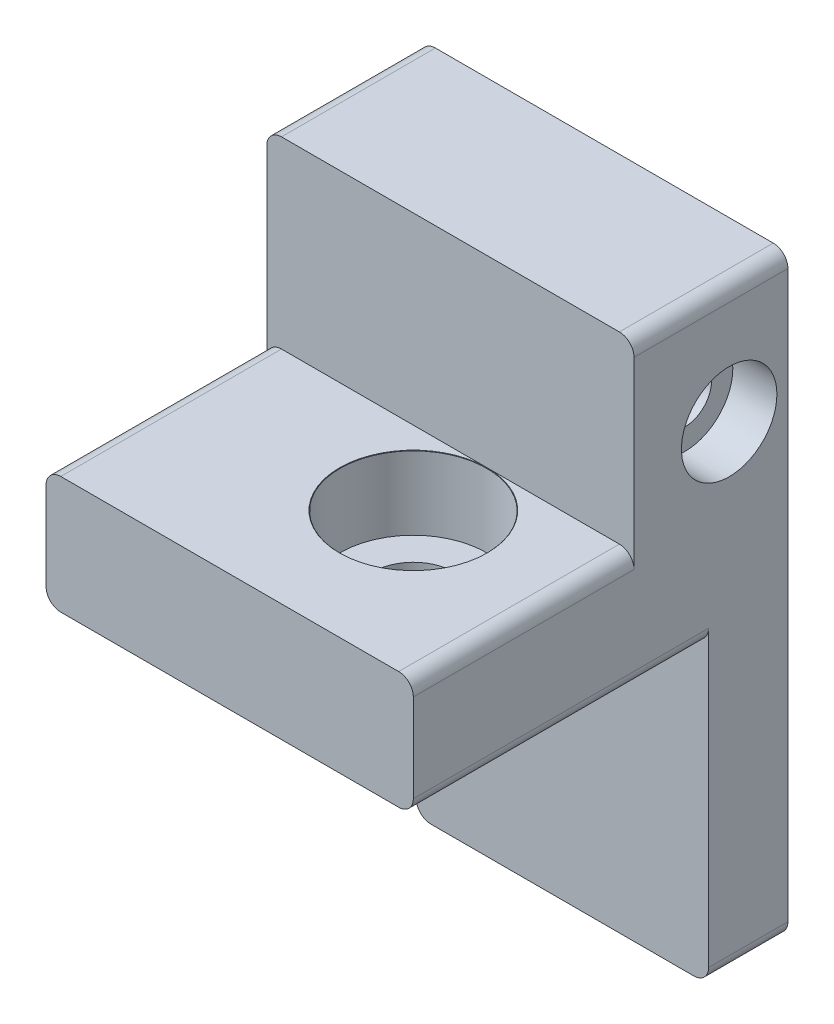
from build123d import *

# Parameters (mm, degrees)
BOSS_EXTRUDE1_DEPTH            = 8
CBORE_FOR_M5_SHCS1_AT_2_COUNT  = 2
CBORE_FOR_M5_SHCS1_AT_2_PITCH  = 20
SKETCH5_W                      = 25
SKETCH5_H                      = 2.975
BOSS_EXTRUDE2_DEPTH            = 12.51
SKETCH6_W                      = 3
SKETCH6_H                      = 8.01
BOSS_EXTRUDE3_DEPTH            = 7.5
BOSS_EXTRUDE4_DEPTH            = 5.5
SKETCH8_W                      = 17
SKETCH8_H                      = 1.25
BOSS_EXTRUDE5_DEPTH            = 7.5
BOSS_EXTRUDE6_DEPTH            = 5.4
FILLET2_R                      = 1
CBORE_FOR_M3_SHCS1_D           = 3.6
CBORE_FOR_M3_SHCS1_DEPTH       = 5
CBORE_FOR_M3_SHCS1_CBORE_D     = 6.5
CBORE_FOR_M3_SHCS1_CBORE_DEPTH = 3
SKETCH13_R                     = 2.4
CUT_EXTRUDE1_DEPTH             = 3.8
SKETCH14_R                     = 1.65
CUT_EXTRUDE2_DEPTH             = 3
SKETCH15_W                     = 20
SKETCH15_H                     = 20
CUT_EXTRUDE3_DEPTH             = 29
SKETCH16_W                     = 17
SKETCH16_H                     = 0.2
SKETCH16_W_2                   = 3
SKETCH16_H_2                   = 0.3
CUT_EXTRUDE4_DEPTH             = 7.5


with BuildPart() as part:
    # Sketch1 → Boss-Extrude1 (new body)
    with BuildSketch(Plane(origin=(0, 0, 0), x_dir=(1, 0, 0), z_dir=(0, 1, 0))):
        Polygon((-10, 0), (-15, 0), (-15, 20), (-10, 20), (10, 20), (10, -20), (-10, -20), align=None)
    extrude(amount=BOSS_EXTRUDE1_DEPTH)

    # Sketch4 → CBORE for M5 SHCS1 (revolve, cut)
    with BuildSketch(Plane(origin=(0, 8, -10), x_dir=(0, 0, 1), z_dir=(1, 0, 0))):
        Polygon((0, 0), (0, 8), (2.75, 8), (2.75, 5), (5, 5), (5, 0.025), (5.025, 0), align=None)
    cbore_for_m5_shcs1 = revolve(axis=Axis((0, 14.35, -10), (0, -1, 0)), mode=Mode.SUBTRACT)

    # CBORE for M5 SHCS1 at 2: CBORE for M5 SHCS1 ×2
    with Locations(*[(0, 0, i * CBORE_FOR_M5_SHCS1_AT_2_PITCH) for i in range(1, CBORE_FOR_M5_SHCS1_AT_2_COUNT)]):
        add(cbore_for_m5_shcs1, mode=Mode.SUBTRACT)

    # Sketch5 → Boss-Extrude2 (add)
    with BuildSketch(Plane(origin=(0, 8, 0), x_dir=(1, 0, 0), z_dir=(0, 1, 0))):
        with Locations((-2.5, 16.5125)):
            Rectangle(SKETCH5_W, SKETCH5_H)
    extrude(amount=BOSS_EXTRUDE2_DEPTH)

    # Sketch6 → Boss-Extrude3 (add)
    with BuildSketch(Plane(origin=(0, 0, -18), x_dir=(-1, 0, 0), z_dir=(0, 0, -1))):
        Polygon((-10, 20.51), (15, 20.51), (15, 17.51), (-5, 17.51), (-5, 8), (-10, 8), (-10, 20), align=None)
        with Locations((13.5, 12.005)):
            Rectangle(SKETCH6_W, SKETCH6_H)
    extrude(amount=BOSS_EXTRUDE3_DEPTH)

    # Sketch7 → Boss-Extrude4 (add)
    with BuildSketch(Plane(origin=(0, 0, -20), x_dir=(-1, 0, 0), z_dir=(0, 0, -1))):
        Polygon((-10, 0), (15, 0), (15, 8), (12, 8), (-5, 8), (-10, 8), align=None)
    extrude(amount=BOSS_EXTRUDE4_DEPTH)

    # Sketch8 → Boss-Extrude5 (add)
    with BuildSketch(Plane(origin=(0, 0, -18), x_dir=(-1, 0, 0), z_dir=(0, 0, -1))):
        with Locations((3.5, 8.625)):
            Rectangle(SKETCH8_W, SKETCH8_H)
    extrude(amount=BOSS_EXTRUDE5_DEPTH)

    # Sketch9 → Boss-Extrude6 (add)
    with BuildSketch(Plane(origin=(0, 0, -25.5), x_dir=(-1, 0, 0), z_dir=(0, 0, -1))):
        Polygon((-10, 0), (15, 0), (15, -5.4), (9.9, -5.4), (9.9, -20), (-10, -20), align=None)
    extrude(amount=-BOSS_EXTRUDE6_DEPTH)

    # Fillet2
    fillet2_edges = [part.edges().sort_by_distance(p)[0] for p in [
        (10, 0, -0.05),
        (-15, 0, -10.05),
        (10, -20, -22.8),
        (-15, -5.4, -22.8),
        (-9.9, -20, -22.8),
        (-10, 8, 10),
        (-15, 8, -7.5125),
        (-15, 20.51, -20.2625),
        (10, 20.51, -20.2625),
        (10, 8, 2.4875),
    ]]
    fillet(fillet2_edges, radius=FILLET2_R)

    # CBORE for M3 SHCS1
    with Locations(Plane(origin=(10, 0, 0), x_dir=(0, 0, -1), z_dir=(1, 0, 0))):
        with Locations((21.5, 12.48)):
            CounterBoreHole(CBORE_FOR_M3_SHCS1_D / 2, CBORE_FOR_M3_SHCS1_CBORE_D / 2, CBORE_FOR_M3_SHCS1_CBORE_DEPTH, depth=CBORE_FOR_M3_SHCS1_DEPTH)

    # Sketch13 → Cut-Extrude1 (cut)
    with BuildSketch(Plane(origin=(0, 0, -25.5), x_dir=(-1, 0, 0), z_dir=(0, 0, -1))):
        with Locations((10, 4)):
            Circle(SKETCH13_R)
        with Locations((-5, 4)):
            Circle(SKETCH13_R)
    extrude(amount=-CUT_EXTRUDE1_DEPTH, mode=Mode.SUBTRACT)

    # Sketch14 → Cut-Extrude2 (cut)
    with BuildSketch(Plane(origin=(0, 0, -21.7), x_dir=(-1, 0, 0), z_dir=(0, 0, -1))):
        with Locations((-5, 4)):
            Circle(SKETCH14_R)
        with Locations((10, 4)):
            Circle(SKETCH14_R)
    extrude(amount=-CUT_EXTRUDE2_DEPTH, mode=Mode.SUBTRACT)

    # Sketch15 → Cut-Extrude3 (cut, through all)
    with BuildSketch(Plane(origin=(0, 8, 0), x_dir=(1, 0, 0), z_dir=(0, 1, 0))):
        with Locations((0, -10)):
            Rectangle(SKETCH15_W, SKETCH15_H)
    extrude(amount=-CUT_EXTRUDE3_DEPTH, mode=Mode.SUBTRACT)

    # Sketch16 → Cut-Extrude4 (cut)
    with BuildSketch(Plane(origin=(0, 0, -25.5), x_dir=(-1, 0, 0), z_dir=(0, 0, -1))):
        with Locations((3.5, 9.15)):
            Rectangle(SKETCH16_W, SKETCH16_H)
        with Locations((13.5, 15.86)):
            Rectangle(SKETCH16_W_2, SKETCH16_H_2)
    extrude(amount=-CUT_EXTRUDE4_DEPTH, mode=Mode.SUBTRACT)


solid = part.part
